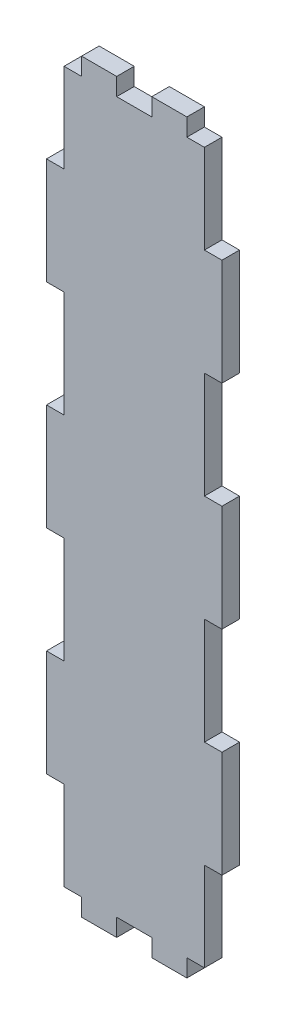
from build123d import *

# Parameters (mm, degrees)
BUITENAFMETING_RECHTHOEK_W  = 40
BUITENAFMETING_RECHTHOEK_H  = 170
PLAAT_DEPTH                 = 4
TAND_HOR_W                  = 8
TAND_HOR_H                  = 4
TAND_BOVEN_DEPTH            = 5
TANDEN_PATROON_BOVEN_COUNT  = 3
TANDEN_PATROON_BOVEN_PITCH  = 16
TAND_VER_W                  = 4
TAND_VER_H                  = 24.285714286
TAND_LINKS_DEPTH            = 5
TANDEN_PATROON_LINKS_COUNT  = 4
TANDEN_PATROON_LINKS_PITCH  = 48.571428571
TAND_O_W                    = 8
TAND_O_H                    = 4
TAND_ONDER_DEPTH            = 5
TANDEN_PATROON_ONDER_COUNT  = 3
TANDEN_PATROON_ONDER_PITCH  = 16
TAND_R_W                    = 4
TAND_R_H                    = 24.285714286
TAND_RECHTS_DEPTH           = 5
TANDEN_PATROON_RECHTS_COUNT = 4
TANDEN_PATROON_RECHTS_PITCH = 48.571428571


with BuildPart() as part:
    # Buitenafmeting Rechthoek → Plaat (new body)
    with BuildSketch(Plane.XY):
        with Locations((20, 85)):
            Rectangle(BUITENAFMETING_RECHTHOEK_W, BUITENAFMETING_RECHTHOEK_H)
    extrude(amount=-PLAAT_DEPTH)

    # Tand Hor → Tand Boven (cut, through all)
    with BuildSketch(Plane.XY):
        with Locations((4, 168)):
            Rectangle(TAND_HOR_W, TAND_HOR_H)
    tand_boven = extrude(amount=-TAND_BOVEN_DEPTH, mode=Mode.SUBTRACT)

    # Tanden Patroon Boven: Tand Boven ×3
    with Locations(*[(i * TANDEN_PATROON_BOVEN_PITCH, 0, 0) for i in range(1, TANDEN_PATROON_BOVEN_COUNT)]):
        add(tand_boven, mode=Mode.SUBTRACT)

    # Tand Ver → Tand Links (cut, through all)
    with BuildSketch(Plane.XY):
        with Locations((2, 157.857142857)):
            Rectangle(TAND_VER_W, TAND_VER_H)
    tand_links = extrude(amount=-TAND_LINKS_DEPTH, mode=Mode.SUBTRACT)

    # Tanden Patroon Links: Tand Links ×4
    with Locations(*[(0, -i * TANDEN_PATROON_LINKS_PITCH, 0) for i in range(1, TANDEN_PATROON_LINKS_COUNT)]):
        add(tand_links, mode=Mode.SUBTRACT)

    # Tand O → Tand Onder (cut, through all)
    with BuildSketch(Plane.XY):
        with Locations((4, 2)):
            Rectangle(TAND_O_W, TAND_O_H)
    tand_onder = extrude(amount=-TAND_ONDER_DEPTH, mode=Mode.SUBTRACT)

    # Tanden Patroon Onder: Tand Onder ×3
    with Locations(*[(i * TANDEN_PATROON_ONDER_PITCH, 0, 0) for i in range(1, TANDEN_PATROON_ONDER_COUNT)]):
        add(tand_onder, mode=Mode.SUBTRACT)

    # Tand R → Tand Rechts (cut, through all)
    with BuildSketch(Plane.XY):
        with Locations((38, 157.857142857)):
            Rectangle(TAND_R_W, TAND_R_H)
    tand_rechts = extrude(amount=-TAND_RECHTS_DEPTH, mode=Mode.SUBTRACT)

    # Tanden Patroon Rechts: Tand Rechts ×4
    with Locations(*[(0, -i * TANDEN_PATROON_RECHTS_PITCH, 0) for i in range(1, TANDEN_PATROON_RECHTS_COUNT)]):
        add(tand_rechts, mode=Mode.SUBTRACT)


solid = part.part
